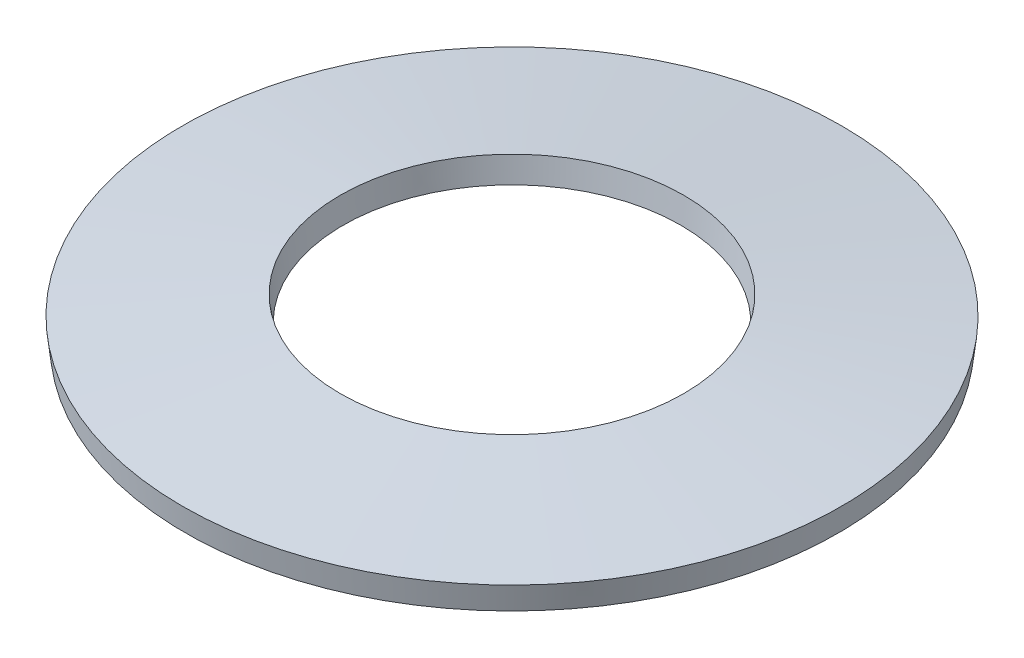
from build123d import *


with BuildPart() as part:
    # Sketch1 → Revolve1 (revolve)
    with BuildSketch(Plane.XY):
        Polygon((7.929332601, 0), (4.1, 0.454176101), (4.170667399, 1.05), (8, 0.595823899), align=None)
    revolve(axis=Axis((0, 0, 0), (0, 1, 0)))


solid = part.part
